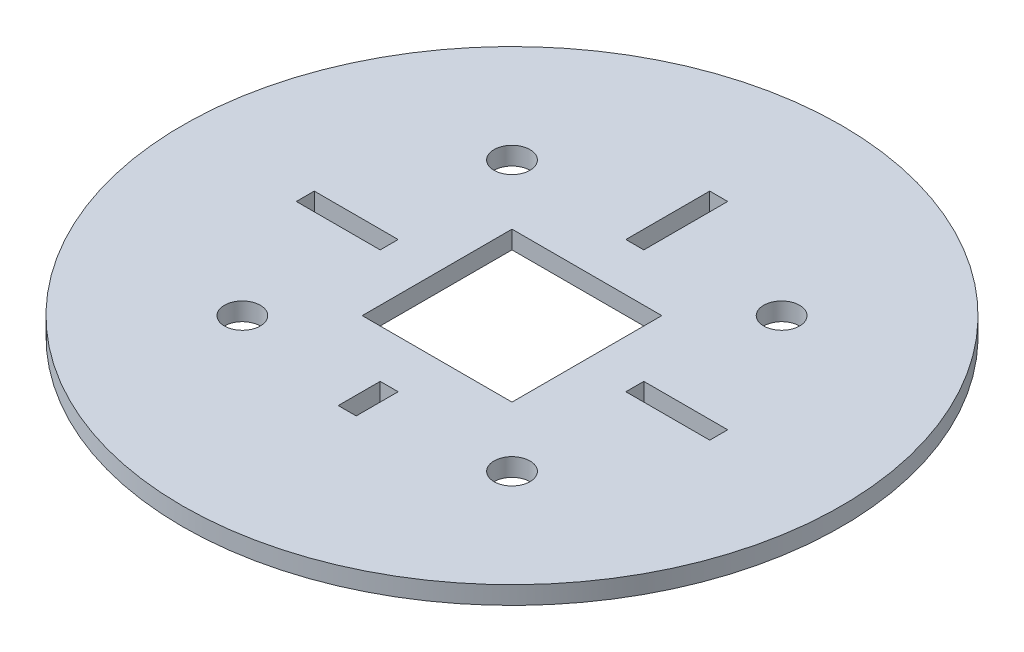
from build123d import *

# Parameters (mm, degrees)
SKETCH1_R           = 55
BOSS_EXTRUDE1_DEPTH = 3
SKETCH2_R           = 3
SKETCH2_W           = 25
SKETCH2_H           = 25
SKETCH2_W_2         = 3
SKETCH2_H_2         = 14
SKETCH2_W_3         = 14
SKETCH2_H_3         = 3
SKETCH2_H_4         = 7
CUT_EXTRUDE1_DEPTH  = 3


with BuildPart() as part:
    # Sketch1 → Boss-Extrude1 (new body)
    with BuildSketch(Plane(origin=(0, 0, 0), x_dir=(1, 0, 0), z_dir=(0, 1, 0))):
        Circle(SKETCH1_R)
    extrude(amount=BOSS_EXTRUDE1_DEPTH)

    # Sketch2 → Cut-Extrude1 (cut)
    with BuildSketch(Plane(origin=(0, 3, 0), x_dir=(1, 0, 0), z_dir=(0, 1, 0))):
        with Locations((-22.5, 22.5)):
            Circle(SKETCH2_R)
        with Locations((22.5, 22.5)):
            Circle(SKETCH2_R)
        with Locations((22.5, -22.5)):
            Circle(SKETCH2_R)
        with Locations((-22.5, -22.5)):
            Circle(SKETCH2_R)
        Rectangle(SKETCH2_W, SKETCH2_H)
        with Locations((0, 27.5)):
            Rectangle(SKETCH2_W_2, SKETCH2_H_2)
        with Locations((-27.5, 0)):
            Rectangle(SKETCH2_W_3, SKETCH2_H_3)
        with Locations((27.5, 0)):
            Rectangle(SKETCH2_W_3, SKETCH2_H_3)
        with Locations((0, -24)):
            Rectangle(SKETCH2_W_2, SKETCH2_H_4)
    extrude(amount=-CUT_EXTRUDE1_DEPTH, mode=Mode.SUBTRACT)


solid = part.part
